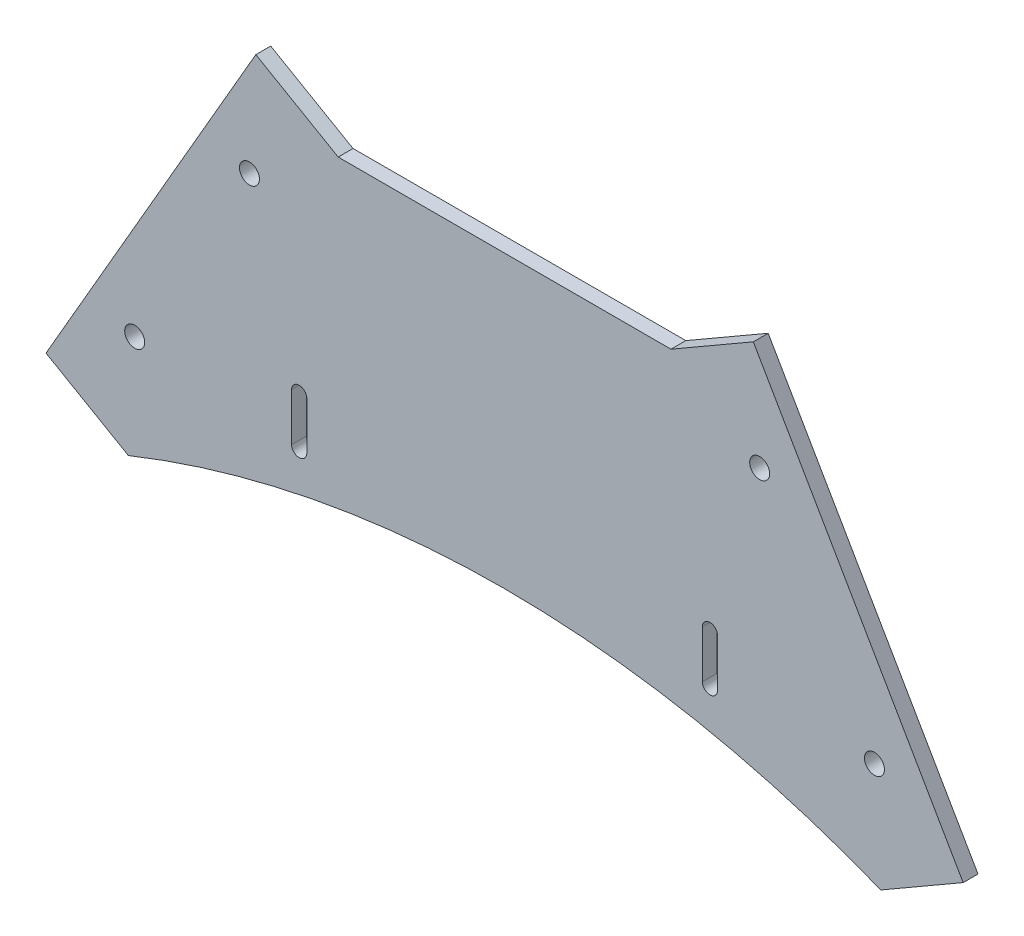
from build123d import *

# Parameters (mm, degrees)
MODEL_R             = 2.1
BOSS_EXTRUDE1_DEPTH = 3.125


with BuildPart() as part:
    # Model → Boss-Extrude1 (new body)
    with BuildSketch(Plane.XY):
        with BuildLine():
            Line((175.590993043, 0), (192.911501119, 10))
            Line((192.911501119, 10), (148.776258635, 86.444482386))
            Line((148.776258635, 86.444482386), (131.455750559, 76.444482386))
            Line((131.455750559, 76.444482386), (61.455750559, 76.444482386))
            Line((61.455750559, 76.444482386), (44.135242484, 86.444482386))
            Line((44.135242484, 86.444482386), (0, 10))
            Line((0, 10), (17.320508076, 0))
            ThreePointArc((17.320508076, 0), (96.455750559, 15.314685), (175.590993043, 0))
        make_face()
        with Locations((42.795496522, 64.123974311)):
            Circle(MODEL_R, mode=Mode.SUBTRACT)
        with Locations((18.660254038, 22.320508076)):
            Circle(MODEL_R, mode=Mode.SUBTRACT)
        with Locations((150.116004597, 64.123974311)):
            Circle(MODEL_R, mode=Mode.SUBTRACT)
        with Locations((174.251247081, 22.320508076)):
            Circle(MODEL_R, mode=Mode.SUBTRACT)
        with BuildLine():
            Line((54.855750559, 29.174833766), (54.855750559, 19.174833766))
            ThreePointArc((54.855750559, 19.174833766), (53.255750559, 17.574833766), (51.655750559, 19.174833766))
            Line((51.655750559, 19.174833766), (51.655750559, 29.174833766))
            ThreePointArc((51.655750559, 29.174833766), (53.255750559, 30.774833766), (54.855750559, 29.174833766))
        make_face(mode=Mode.SUBTRACT)
        with BuildLine():
            Line((141.255750559, 29.174833766), (141.255750559, 19.174833766))
            ThreePointArc((141.255750559, 19.174833766), (139.655750559, 17.574833766), (138.055750559, 19.174833766))
            Line((138.055750559, 19.174833766), (138.055750559, 29.174833766))
            ThreePointArc((138.055750559, 29.174833766), (139.655750559, 30.774833766), (141.255750559, 29.174833766))
        make_face(mode=Mode.SUBTRACT)
    extrude(amount=BOSS_EXTRUDE1_DEPTH)


solid = part.part
